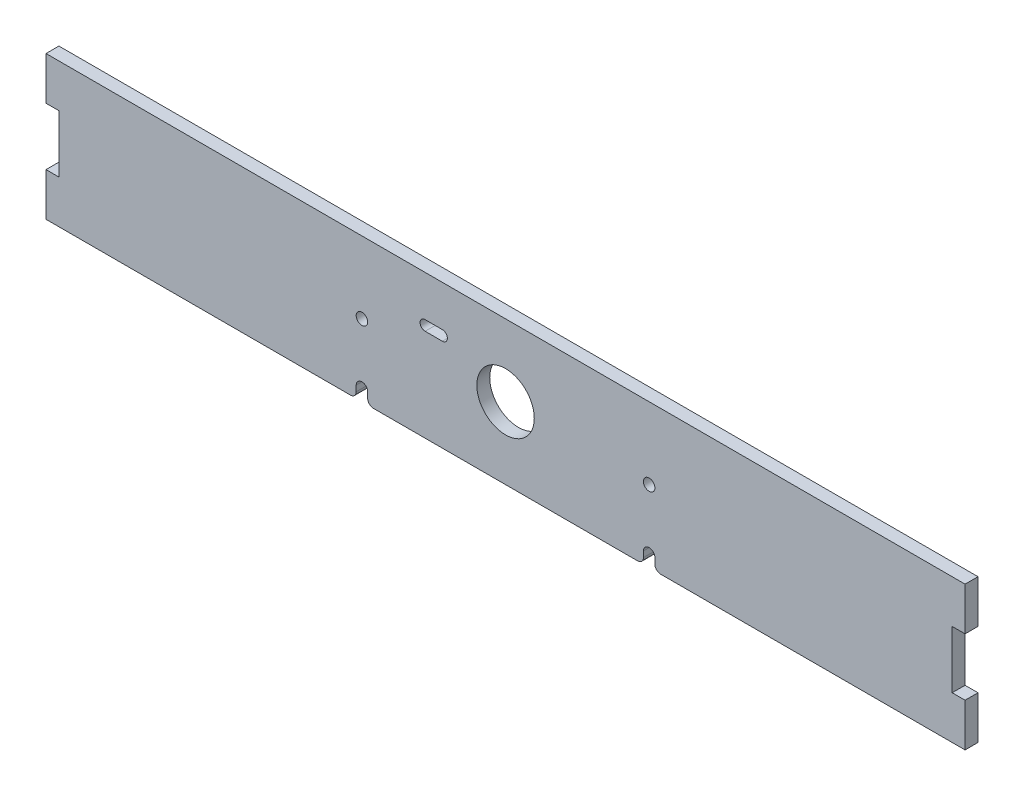
from build123d import *

# Parameters (mm, degrees)
SKETCH1_W                        = 406.4
SKETCH1_H                        = 63.5
BOSS_EXTRUDE1_DEPTH              = 5.715
SKETCH2_R                        = 12.7
SEED_HOLE_DEPTH                  = 6.715
SEED_HOLE_DEPTH_BACK             = 1
SKETCH3_R                        = 2.54
LED_MOUNT_DEPTH                  = 6.715
IR_SENSOR_WIRE_KEEPER_DEPTH      = 1
IR_SENSOR_WIRE_KEEPER_DEPTH_BACK = 6.715
FILLET1_R                        = 2.54
SEED_SWITCH_MOUNT_DEPTH          = 6.715
SKETCH6_W                        = 5.715
SKETCH6_H                        = 25.4
CUT_EXTRUDE6_DEPTH               = 6.715


with BuildPart() as part:
    # Sketch1 → Boss-Extrude1 (new body)
    with BuildSketch(Plane.XY):
        Rectangle(SKETCH1_W, SKETCH1_H)
    extrude(amount=BOSS_EXTRUDE1_DEPTH)

    # Sketch2 → Seed Hole (cut, two sides)
    with BuildSketch(Plane.XY) as seed_hole_sk:
        Circle(SKETCH2_R)
    extrude(amount=SEED_HOLE_DEPTH, mode=Mode.SUBTRACT)
    extrude(seed_hole_sk.sketch, amount=-SEED_HOLE_DEPTH_BACK, mode=Mode.SUBTRACT)

    # Sketch3 → LED Mount (cut, through all)
    with BuildSketch(Plane.XY):
        with Locations((-63.5, 0)):
            Circle(SKETCH3_R)
        with Locations((63.5, 0)):
            Circle(SKETCH3_R)
    extrude(amount=LED_MOUNT_DEPTH, mode=Mode.SUBTRACT)

    # Sketch4 → IR Sensor Wire Keeper (cut, two sides)
    with BuildSketch(Plane.XY.offset(5.715)) as ir_sensor_wire_keeper_sk:
        with BuildLine():
            Line((-60.96, -26.67), (-60.96, -36.83))
            ThreePointArc((-60.96, -36.83), (-63.5, -39.37), (-66.04, -36.83))
            Line((-66.04, -36.83), (-66.04, -26.67))
            ThreePointArc((-66.04, -26.67), (-63.5, -24.13), (-60.96, -26.67))
        make_face()
        with BuildLine():
            Line((66.04, -26.67), (66.04, -36.83))
            ThreePointArc((66.04, -36.83), (63.5, -39.37), (60.96, -36.83))
            Line((60.96, -36.83), (60.96, -26.67))
            ThreePointArc((60.96, -26.67), (63.5, -24.13), (66.04, -26.67))
        make_face()
    extrude(amount=IR_SENSOR_WIRE_KEEPER_DEPTH, mode=Mode.SUBTRACT)
    extrude(ir_sensor_wire_keeper_sk.sketch, amount=-IR_SENSOR_WIRE_KEEPER_DEPTH_BACK, mode=Mode.SUBTRACT)

    # Fillet1
    fillet1_edges = [part.edges().sort_by_distance(p)[0] for p in [
        (-60.96, -31.75, 2.8575),
        (-66.04, -31.75, 2.8575),
        (66.04, -31.75, 2.8575),
        (60.96, -31.75, 2.8575),
    ]]
    fillet(fillet1_edges, radius=FILLET1_R)

    # Sketch5 → Seed Switch Mount (cut, through all)
    with BuildSketch(Plane.XY.offset(5.715)):
        with BuildLine():
            Line((-35.56, 13.6525), (-27.94, 13.6525))
            ThreePointArc((-27.94, 13.6525), (-25.7175, 11.43), (-27.94, 9.2075))
            Line((-27.94, 9.2075), (-35.56, 9.2075))
            ThreePointArc((-35.56, 9.2075), (-37.7825, 11.43), (-35.56, 13.6525))
        make_face()
    extrude(amount=-SEED_SWITCH_MOUNT_DEPTH, mode=Mode.SUBTRACT)

    # Sketch6 → Cut-Extrude6 (cut, through all)
    with BuildSketch(Plane.XY.offset(5.715)):
        with Locations((-200.3425, 0)):
            Rectangle(SKETCH6_W, SKETCH6_H)
    cut_extrude6 = extrude(amount=-CUT_EXTRUDE6_DEPTH, mode=Mode.SUBTRACT)

    # Mirror1: Cut-Extrude6 across plane
    add(cut_extrude6.mirror(Plane(origin=(0, 0, 0), x_dir=(0, 0, 1), z_dir=(1, 0, 0))), mode=Mode.SUBTRACT)


solid = part.part
